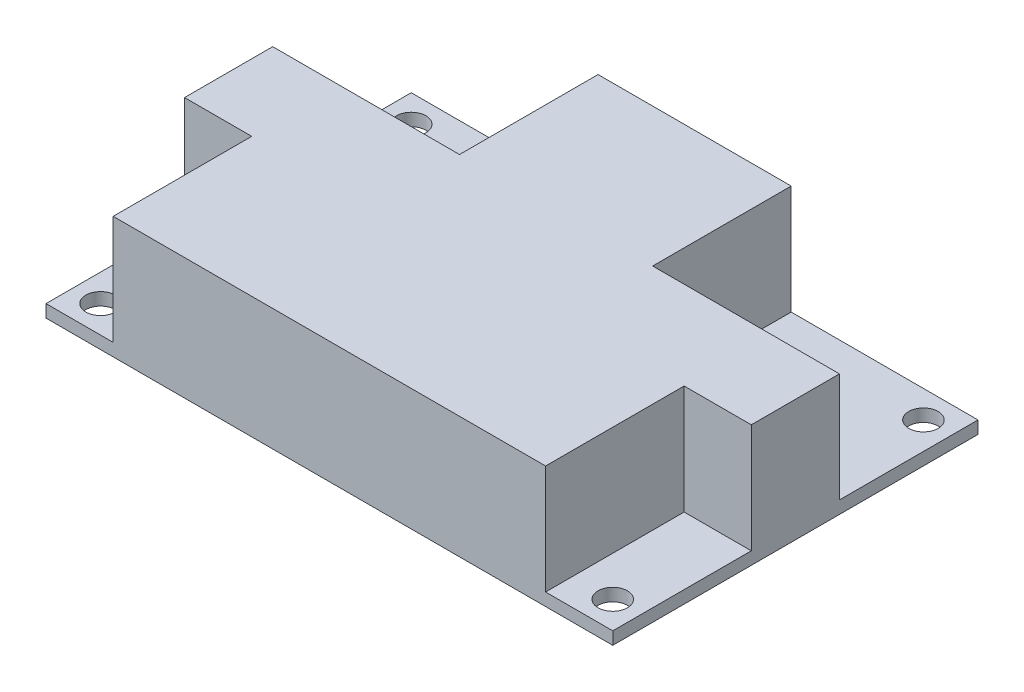
from build123d import *

# Parameters (mm, degrees)
ESQUISSE1_W        = 67.5
ESQUISSE1_H        = 43.5
ESQUISSE1_R        = 1.75
BOSS_EXTRU_1_DEPTH = 1.5
BOSS_EXTRU_2_DEPTH = 13


with BuildPart() as part:
    # Esquisse1 → Boss.-Extru.1 (new body)
    with BuildSketch(Plane(origin=(0, 0, 0), x_dir=(1, 0, 0), z_dir=(0, 1, 0))):
        with Locations((33.75, 21.75)):
            Rectangle(ESQUISSE1_W, ESQUISSE1_H)
        with Locations((3.25, 40.25)):
            Circle(ESQUISSE1_R, mode=Mode.SUBTRACT)
        with Locations((64.25, 40.25)):
            Circle(ESQUISSE1_R, mode=Mode.SUBTRACT)
        with Locations((64.25, 3.25)):
            Circle(ESQUISSE1_R, mode=Mode.SUBTRACT)
        with Locations((3.25, 3.25)):
            Circle(ESQUISSE1_R, mode=Mode.SUBTRACT)
    extrude(amount=BOSS_EXTRU_1_DEPTH)

    # Esquisse3 → Boss.-Extru.2 (add)
    with BuildSketch(Plane(origin=(0, 1.5, 0), x_dir=(1, 0, 0), z_dir=(0, 1, 0))):
        Polygon((45.25, 43.5), (22.25, 43.5), (22.25, 27), (0, 27), (0, 16.5), (8, 16.5), (8, 0), (59.5, 0), (59.5, 16.5), (67.5, 16.5), (67.5, 27), (45.25, 27), align=None)
    extrude(amount=BOSS_EXTRU_2_DEPTH)


solid = part.part
